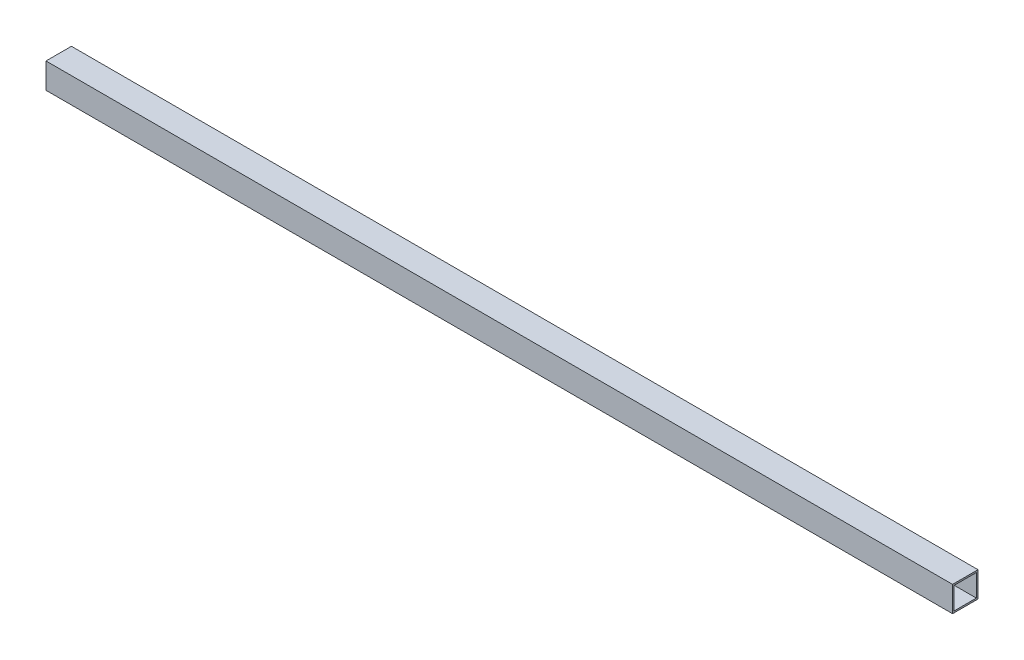
from build123d import *

# Parameters (mm, degrees)
SKETCH13_W                                     = 25.4
SKETCH13_H                                     = 25.4
SKETCH13_W_2                                   = 22.098
SKETCH13_H_2                                   = 22.098
AL_TUBE_SQUARE_AL_TUBE_1_SQR_X_0_065_WAL_DEPTH = 905.4


with BuildPart() as part:
    # Sketch13 → Al tube square AL TUBE 1 SQR X 0.065 WALL(1) (new body)
    with BuildSketch(Plane.YZ):
        Rectangle(SKETCH13_W, SKETCH13_H)
        Rectangle(SKETCH13_W_2, SKETCH13_H_2, mode=Mode.SUBTRACT)
    extrude(amount=AL_TUBE_SQUARE_AL_TUBE_1_SQR_X_0_065_WAL_DEPTH)


solid = part.part
